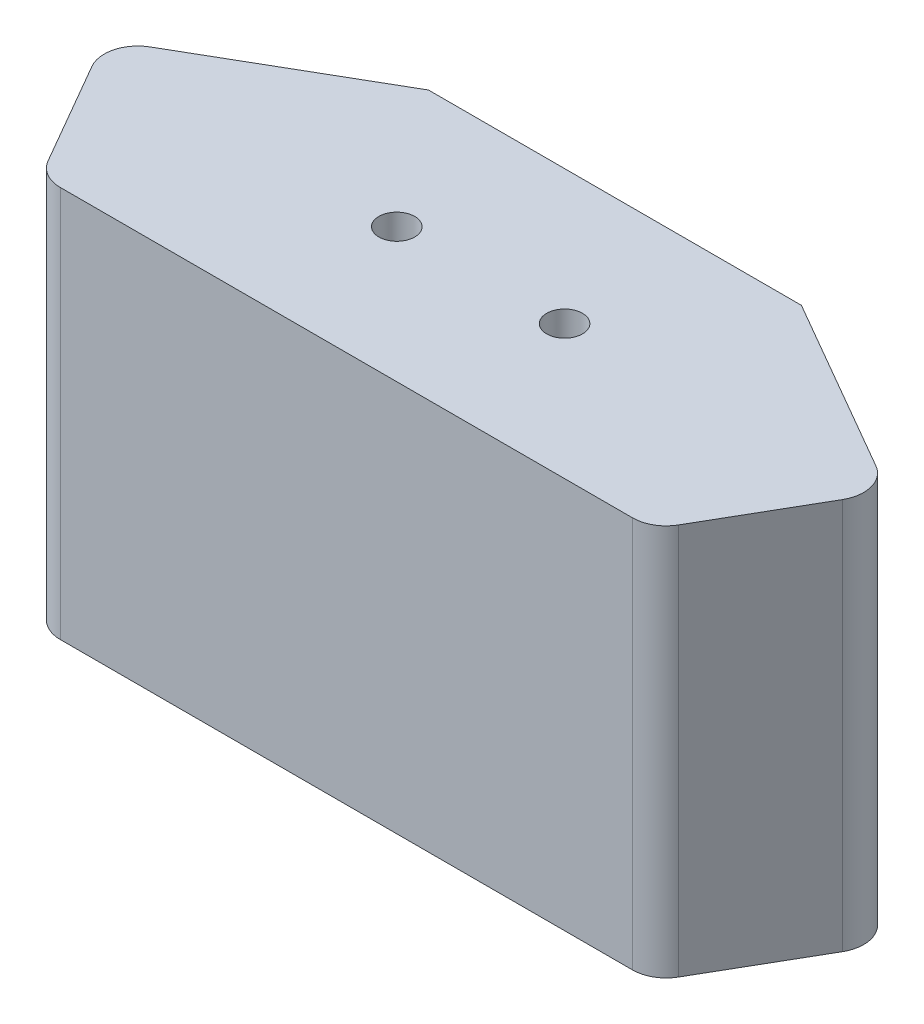
from build123d import *

# Parameters (mm, degrees)
EXTRUDE_1_DEPTH             = 35
HOLE_WIZARD_M3_1_AT_2_COUNT = 2
HOLE_WIZARD_M3_1_AT_2_PITCH = 15


with BuildPart() as part:
    # 草圖1 → 填料-伸長1 (new body)
    with BuildSketch(Plane(origin=(0, 35, 0), x_dir=(1, 0, 0), z_dir=(0, 1, 0))):
        with BuildLine():
            Line((8.333333333, 20), (-7.442946108, 10.891560818))
            ThreePointArc((-7.442946108, 10.891560818), (-8.840723587, 9.069941742), (-8.54102232, 6.793484606))
            Line((-8.54102232, 6.793484606), (-3.175426481, -2.5))
            ThreePointArc((-3.175426481, -2.5), (-2.077350269, -3.598076211), (-0.577350269, -4))
            Line((-0.577350269, -4), (50.577350269, -4))
            ThreePointArc((50.577350269, -4), (52.077350269, -3.598076211), (53.175426481, -2.5))
            Line((53.175426481, -2.5), (58.54102232, 6.793484606))
            ThreePointArc((58.54102232, 6.793484606), (58.840723587, 9.069941742), (57.442946108, 10.891560818))
            Line((57.442946108, 10.891560818), (41.666666667, 20))
            Line((41.666666667, 20), (8.333333333, 20))
        make_face()
    extrude(amount=-EXTRUDE_1_DEPTH)

    # 草圖2 → M3 平頭機械螺釘的錐孔1 (revolve, cut)
    with BuildSketch(Plane(origin=(17.5, 0, -8), x_dir=(0, 0, -1), z_dir=(1, 0, 0))):
        Polygon((0, 0), (0, 35), (1.6, 35), (1.6, 28.7), (3.3, 27), (3.3, 0), align=None)
    hole_wizard_m3_1 = revolve(axis=Axis((17.5, -6.35, -8), (0, 1, 0)), mode=Mode.SUBTRACT)

    # M3 平頭機械螺釘的錐孔1 at 2: M3 平頭機械螺釘的錐孔1 ×2
    with Locations(*[(i * HOLE_WIZARD_M3_1_AT_2_PITCH, 0, 0) for i in range(1, HOLE_WIZARD_M3_1_AT_2_COUNT)]):
        add(hole_wizard_m3_1, mode=Mode.SUBTRACT)


solid = part.part
